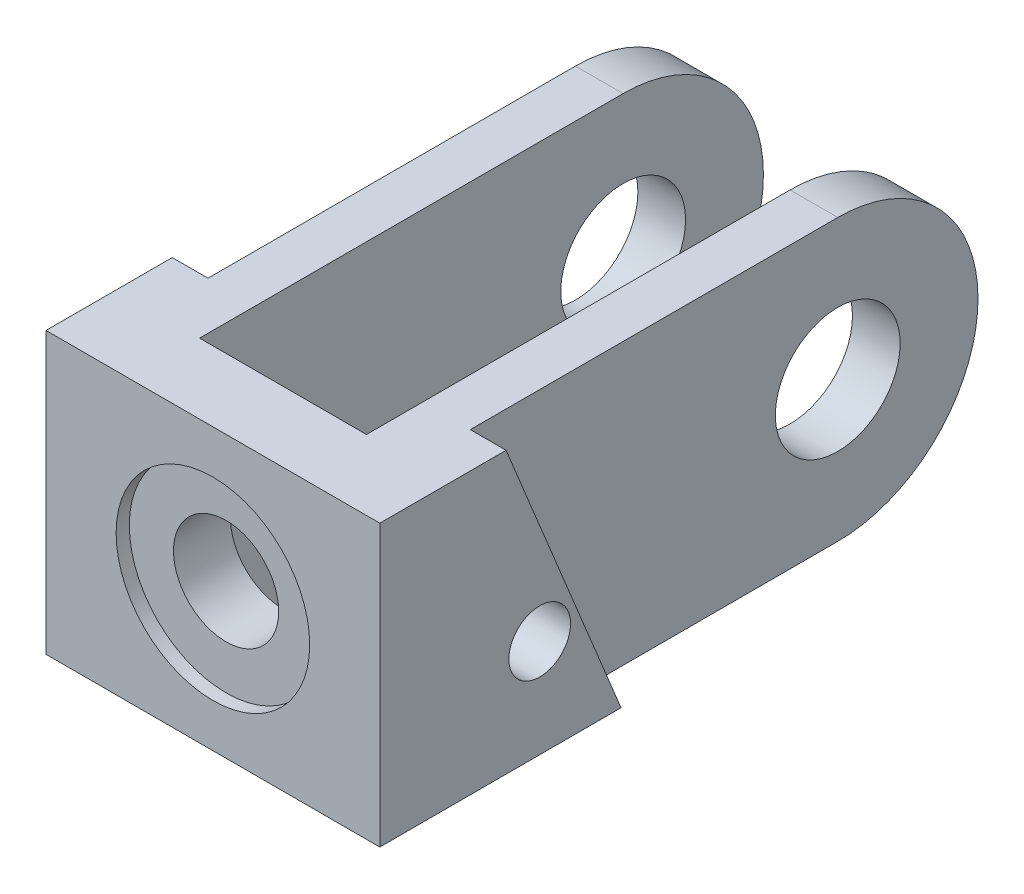
from build123d import *

# Parameters (mm, degrees)
SKETCH1_W           = 12.7
SKETCH1_H           = 50.8
BOSS_EXTRUDE1_DEPTH = 15.113
BOSS_EXTRUDE2_START = 15.113
SKETCH1_3_R         = 5.588
SKETCH1_3_R_2       = 11.303
BOSS_EXTRUDE2_DEPTH = 8.636
BOSS_EXTRUDE3_START = 23.749
SKETCH1_4_R         = 5.588
BOSS_EXTRUDE3_DEPTH = 6.477
SKETCH2_R           = 9.525
CUT_EXTRUDE1_DEPTH  = 130.132211086
SKETCH3_R           = 17.526
CUT_EXTRUDE2_DEPTH  = 2.3876


with BuildPart() as part:
    # Sketch1 → Boss-Extrude1 (new body)
    with BuildSketch(Plane(origin=(0, 0, 0), x_dir=(0, 0, -1), z_dir=(1, 0, 0))):
        with Locations((6.35, 25.4)):
            Rectangle(SKETCH1_W, SKETCH1_H)
    boss_extrude1 = extrude(amount=BOSS_EXTRUDE1_DEPTH)

    # Sketch1_3 → Boss-Extrude2 (add)
    with BuildSketch(Plane(origin=(0, 0, 0), x_dir=(0, 0, -1), z_dir=(1, 0, 0)).offset(BOSS_EXTRUDE2_START)):
        with BuildLine():
            Line((0, 50.8), (0, 0))
            Line((0, 0), (89.408, 0))
            ThreePointArc((89.408, 0), (114.808, 25.4), (89.408, 50.8))
            Line((89.408, 50.8), (0, 50.8))
        make_face()
        with Locations((28.956, 17.78)):
            Circle(SKETCH1_3_R, mode=Mode.SUBTRACT)
        with Locations((89.408, 25.4)):
            Circle(SKETCH1_3_R_2, mode=Mode.SUBTRACT)
    boss_extrude2 = extrude(amount=BOSS_EXTRUDE2_DEPTH)

    # Sketch1_4 → Boss-Extrude3 (add)
    with BuildSketch(Plane(origin=(0, 0, 0), x_dir=(0, 0, -1), z_dir=(1, 0, 0)).offset(BOSS_EXTRUDE3_START)):
        Polygon((0, 50.8), (0, 0), (43.688, 0), (22.86, 50.8), align=None)
        with Locations((28.956, 17.78)):
            Circle(SKETCH1_4_R, mode=Mode.SUBTRACT)
    boss_extrude3 = extrude(amount=BOSS_EXTRUDE3_DEPTH)

    # Mirror1: Boss-Extrude1, Boss-Extrude2, Boss-Extrude3 across plane
    add(boss_extrude1.mirror(Plane(origin=(0, 0, 0), x_dir=(0, 0, 1), z_dir=(1, 0, 0))))
    add(boss_extrude2.mirror(Plane(origin=(0, 0, 0), x_dir=(0, 0, 1), z_dir=(1, 0, 0))))
    add(boss_extrude3.mirror(Plane(origin=(0, 0, 0), x_dir=(0, 0, 1), z_dir=(1, 0, 0))))

    # Sketch2 → Cut-Extrude1 (cut, through all)
    with BuildSketch(Plane.XY):
        with Locations((0, 25.4)):
            Circle(SKETCH2_R)
    extrude(amount=-CUT_EXTRUDE1_DEPTH, mode=Mode.SUBTRACT)

    # Sketch3 → Cut-Extrude2 (cut)
    with BuildSketch(Plane.XY):
        with Locations((0, 25.4)):
            Circle(SKETCH3_R)
    extrude(amount=-CUT_EXTRUDE2_DEPTH, mode=Mode.SUBTRACT)


solid = part.part
